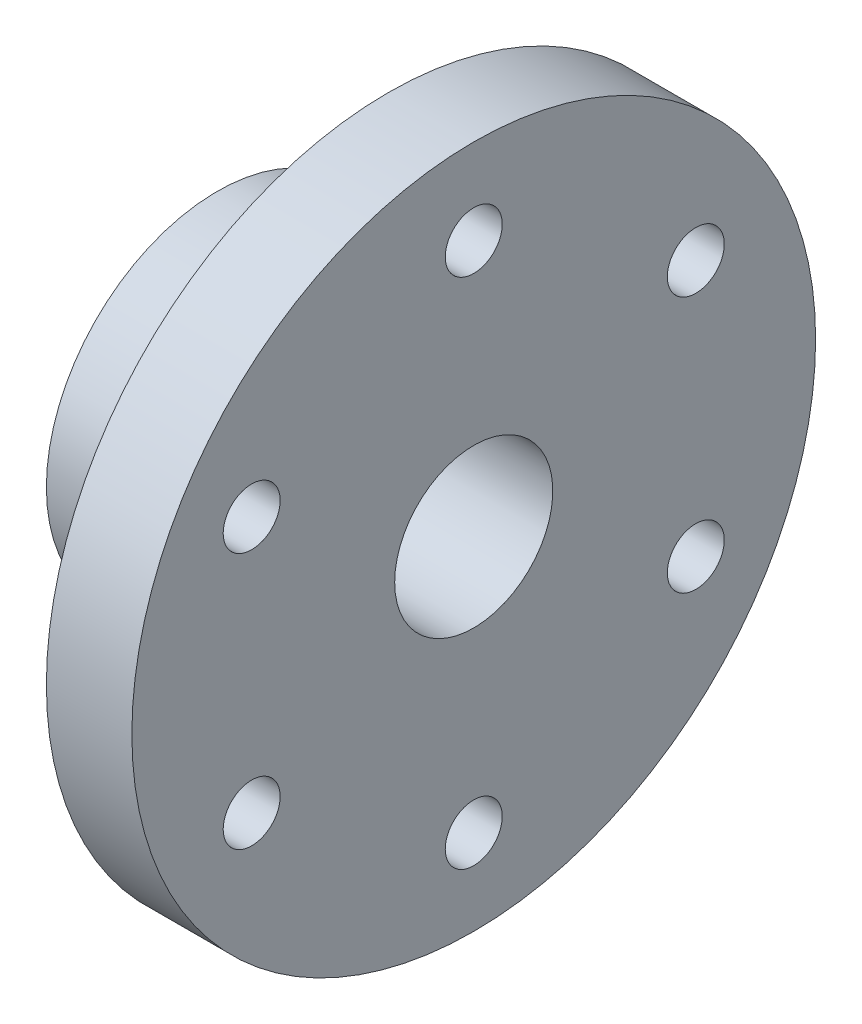
from build123d import *

# Parameters (mm, degrees)
SKETCH2_R          = 4
CUT_EXTRUDE1_DEPTH = 12
CUT_EXTRUDE2_REACH = 74
SKETCH3_R          = 4


with BuildPart() as part:
    # Sketch1 → Revolve1 (revolve)
    with BuildSketch(Plane.XY):
        Polygon((-25.700460829, 11.1), (-25.700460829, 24), (-1.700460829, 24), (-1.700460829, 48), (10.299539171, 48), (10.299539171, 11.1), align=None)
    revolve(axis=Axis((-11.612903226, 0, 0), (1, 0, 0)))

    # Sketch2 → Cut-Extrude1 (cut)
    with BuildSketch(Plane.ZY.offset(1.700460829)):
        with Locations((0, 36)):
            Circle(SKETCH2_R)
        with Locations((31.176914536, 18)):
            Circle(SKETCH2_R)
        with Locations((31.176914536, -18)):
            Circle(SKETCH2_R)
        with Locations((0, -36)):
            Circle(SKETCH2_R)
        with Locations((-31.176914536, -18)):
            Circle(SKETCH2_R)
        with Locations((-31.176914536, 18)):
            Circle(SKETCH2_R)
    extrude(amount=-CUT_EXTRUDE1_DEPTH, mode=Mode.SUBTRACT)

    # Sketch3 → Cut-Extrude2 (cut, up to next)
    with BuildSketch(Plane.XY.offset(24), mode=Mode.PRIVATE) as cut_extrude2_sk1:
        with Locations((-13.700460829, 0)):
            Circle(SKETCH3_R)
    cut_extrude2_tool1 = extrude(cut_extrude2_sk1.sketch, amount=-CUT_EXTRUDE2_REACH, mode=Mode.PRIVATE) & part.part
    add(cut_extrude2_tool1.solids().sort_by_distance((-13.700461, 0, 24))[0], mode=Mode.SUBTRACT)


solid = part.part
